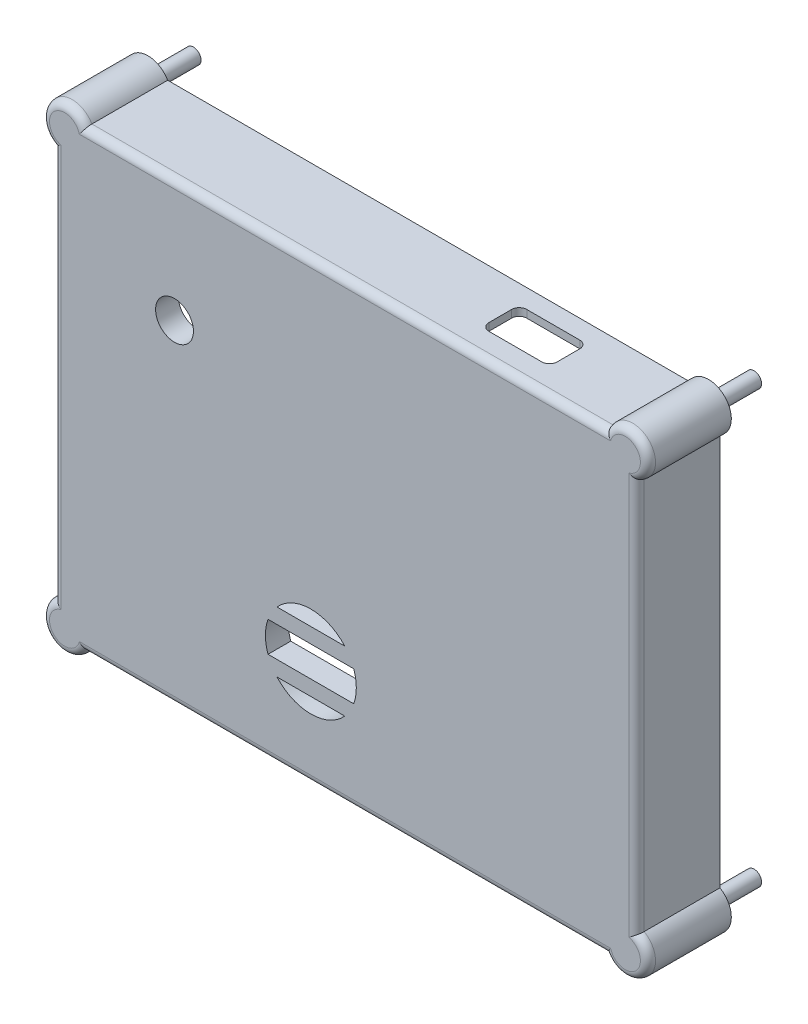
from build123d import *

# Parameters (mm, degrees)
SKETCH2_R                  = 1.75
BOSS_EXTRUDE1_DEPTH        = 8
BOSS_EXTRUDE1_DEPTH_BACK   = 12
BOSS_EXTRUDE1_2_DEPTH      = 8
BOSS_EXTRUDE1_2_DEPTH_BACK = 12
BOSS_EXTRUDE1_3_DEPTH      = 8
BOSS_EXTRUDE1_3_DEPTH_BACK = 12
BOSS_EXTRUDE1_4_DEPTH      = 8
BOSS_EXTRUDE1_4_DEPTH_BACK = 12
SKETCH3_W                  = 77
SKETCH3_H                  = 60
SKETCH3_W_2                = 71
SKETCH3_H_2                = 54
BOSS_EXTRUDE2_DEPTH        = 8
SKETCH4_W                  = 77
SKETCH4_H                  = 60
BOSS_EXTRUDE3_DEPTH        = 3
CUT_EXTRUDE6_DEPTH         = 20
CUT_EXTRUDE8_DEPTH         = 13
CUT_EXTRUDE9_DEPTH         = 10
SKETCH17_R                 = 1
BOSS_EXTRUDE5_DEPTH        = 6
BOSS_EXTRUDE5_DEPTH_BACK   = 7
FILLET1_R                  = 1
BOSS_EXTRUDE6_DEPTH        = 11
FILLET3_R                  = 1
SKETCH20_R                 = 2.5
CUT_EXTRUDE10_DEPTH        = 10
SKETCH22_W                 = 34.401923789
SKETCH22_H                 = 2
CUT_EXTRUDE11_DEPTH        = 8


with BuildPart() as part:
    # Sketch2 → Boss-Extrude1 (new body, two sides)
    with BuildSketch(Plane.XY) as boss_extrude1_sk:
        with BuildLine():
            Line((-35.5, -27), (-25.5, -27))
            ThreePointArc((-25.5, -27), (-28.428932188, -19.928932188), (-35.5, -17))
            Line((-35.5, -17), (-35.5, -27))
        make_face()
        with Locations((-33, -23)):
            Circle(SKETCH2_R, mode=Mode.SUBTRACT)
    extrude(amount=BOSS_EXTRUDE1_DEPTH)
    extrude(boss_extrude1_sk.sketch, amount=-BOSS_EXTRUDE1_DEPTH_BACK)



with BuildPart() as body_2:
    # Sketch2 → Boss-Extrude1 2 (new body, two sides)
    with BuildSketch(Plane.XY) as boss_extrude1_2_sk:
        with BuildLine():
            Line((35.5, 27), (35.5, 17))
            ThreePointArc((35.5, 17), (28.428932188, 19.928932188), (25.5, 27))
            Line((25.5, 27), (35.5, 27))
        make_face()
        with Locations((33, 21)):
            Circle(SKETCH2_R, mode=Mode.SUBTRACT)
    extrude(amount=BOSS_EXTRUDE1_2_DEPTH)
    extrude(boss_extrude1_2_sk.sketch, amount=-BOSS_EXTRUDE1_2_DEPTH_BACK)


with BuildPart() as body_3:
    # Sketch2 → Boss-Extrude1 3 (new body, two sides)
    with BuildSketch(Plane.XY) as boss_extrude1_3_sk:
        with BuildLine():
            Line((-35.5, 27), (-25.5, 27))
            ThreePointArc((-25.5, 27), (-28.428932188, 19.928932188), (-35.5, 17))
            Line((-35.5, 17), (-35.5, 27))
        make_face()
        with Locations((-33, 21)):
            Circle(SKETCH2_R, mode=Mode.SUBTRACT)
    extrude(amount=BOSS_EXTRUDE1_3_DEPTH)
    extrude(boss_extrude1_3_sk.sketch, amount=-BOSS_EXTRUDE1_3_DEPTH_BACK)


with BuildPart() as body_4:
    # Sketch2 → Boss-Extrude1 4 (new body, two sides)
    with BuildSketch(Plane.XY) as boss_extrude1_4_sk:
        with BuildLine():
            Line((35.5, -17), (35.5, -27))
            Line((35.5, -27), (25.5, -27))
            ThreePointArc((25.5, -27), (28.428932188, -19.928932188), (35.5, -17))
        make_face()
        with Locations((33, -23)):
            Circle(SKETCH2_R, mode=Mode.SUBTRACT)
    extrude(amount=BOSS_EXTRUDE1_4_DEPTH)
    extrude(boss_extrude1_4_sk.sketch, amount=-BOSS_EXTRUDE1_4_DEPTH_BACK)


with BuildPart() as part_1:
    add(part.part)

    add(body_2.part)  # Boss-Extrude2 merges body 2

    add(body_3.part)  # Boss-Extrude2 merges body 3

    add(body_4.part)  # Boss-Extrude2 merges body 4
    # Sketch3 → Boss-Extrude2 (add)
    with BuildSketch(Plane.XY):
        Rectangle(SKETCH3_W, SKETCH3_H)
        Rectangle(SKETCH3_W_2, SKETCH3_H_2, mode=Mode.SUBTRACT)
    extrude(amount=BOSS_EXTRUDE2_DEPTH)

    # Sketch4 → Boss-Extrude3 (add)
    with BuildSketch(Plane.XY.offset(8)):
        Rectangle(SKETCH4_W, SKETCH4_H)
    extrude(amount=BOSS_EXTRUDE3_DEPTH)

    # Sketch12 → Cut-Extrude6 (cut)
    with BuildSketch(Plane(origin=(0, 0, -12), x_dir=(-1, 0, 0), z_dir=(0, 0, -1))):
        with BuildLine():
            Line((-35.5, -27), (-25.5, -27))
            ThreePointArc((-25.5, -27), (-28.428932188, -19.928932188), (-35.5, -17))
            Line((-35.5, -17), (-35.5, -27))
        make_face()
        with BuildLine():
            Line((35.5, -27), (35.5, -17))
            ThreePointArc((35.5, -17), (28.428932188, -19.928932188), (25.5, -27))
            Line((25.5, -27), (35.5, -27))
        make_face()
        with BuildLine():
            Line((35.5, 17), (35.5, 27))
            Line((35.5, 27), (25.5, 27))
            ThreePointArc((25.5, 27), (28.428932188, 19.928932188), (35.5, 17))
        make_face()
        with BuildLine():
            Line((-25.5, 27), (-35.5, 27))
            Line((-35.5, 27), (-35.5, 17))
            ThreePointArc((-35.5, 17), (-28.428932188, 19.928932188), (-25.5, 27))
        make_face()
    extrude(amount=-CUT_EXTRUDE6_DEPTH, mode=Mode.SUBTRACT)

    # Sketch14 → Cut-Extrude8 (cut)
    with BuildSketch(Plane(origin=(0, 30, 0), x_dir=(1, 0, 0), z_dir=(0, 1, 0))):
        with BuildLine():
            Line((22.5, -7.5), (15.5, -7.5))
            ThreePointArc((15.5, -7.5), (14.792893219, -7.207106781), (14.5, -6.5))
            Line((14.5, -6.5), (14.5, -3.5))
            ThreePointArc((14.5, -3.5), (14.792893219, -2.792893219), (15.5, -2.5))
            Line((15.5, -2.5), (22.5, -2.5))
            ThreePointArc((22.5, -2.5), (23.207106781, -2.792893219), (23.5, -3.5))
            Line((23.5, -3.5), (23.5, -6.5))
            ThreePointArc((23.5, -6.5), (23.207106781, -7.207106781), (22.5, -7.5))
        make_face()
    extrude(amount=-CUT_EXTRUDE8_DEPTH, mode=Mode.SUBTRACT)

    # Sketch15 → Cut-Extrude9 (cut)
    with BuildSketch(Plane.XY.offset(11)):
        with BuildLine():
            ThreePointArc((-0.027864045, -12), (-4.5, -10), (-8.972135955, -12))
            Line((-8.972135955, -12), (-0.027864045, -12))
        make_face()
        with BuildLine():
            Line((1.156854249, -14), (-10.156854249, -14))
            ThreePointArc((-10.156854249, -14), (-10.5, -16), (-10.156854249, -18))
            Line((-10.156854249, -18), (1.156854249, -18))
            ThreePointArc((1.156854249, -18), (1.413591358, -17.014611872), (1.5, -16))
            ThreePointArc((1.5, -16), (1.413591358, -14.985388128), (1.156854249, -14))
        make_face()
        with BuildLine():
            Line((-0.027864045, -20), (-8.972135955, -20))
            ThreePointArc((-8.972135955, -20), (-4.5, -22), (-0.027864045, -20))
        make_face()
    extrude(amount=-CUT_EXTRUDE9_DEPTH, mode=Mode.SUBTRACT)

    # Sketch17 → Boss-Extrude5 (add, two sides)
    with BuildSketch(Plane(origin=(0, 0, 0), x_dir=(-1, 0, 0), z_dir=(0, 0, -1))) as boss_extrude5_sk:
        with Locations((-37, 28.5)):
            Circle(SKETCH17_R)
        with Locations((37, 28.5)):
            Circle(SKETCH17_R)
        with Locations((37, -28.5)):
            Circle(SKETCH17_R)
        with Locations((-37, -28.472787798)):
            Circle(SKETCH17_R)
    extrude(amount=BOSS_EXTRUDE5_DEPTH)
    extrude(boss_extrude5_sk.sketch, amount=-BOSS_EXTRUDE5_DEPTH_BACK)

    # Fillet1
    fillet1_edges = [part_1.edges().sort_by_distance(p)[0] for p in [
        (-38.5, 30, 5.5),
        (38.5, 30, 5.5),
        (38.5, -30, 5.5),
        (-38.5, -30, 5.5),
    ]]
    fillet(fillet1_edges, radius=FILLET1_R)

    # Sketch19 → Boss-Extrude6 (add)
    with BuildSketch(Plane(origin=(0, 0, 0), x_dir=(-1, 0, 0), z_dir=(0, 0, -1))):
        with BuildLine():
            Line((38.5, 29), (38.5, 25.901923789))
            ThreePointArc((38.5, 25.901923789), (39.121320344, 30.621320344), (34.401923789, 30))
            Line((34.401923789, 30), (37.5, 30))
            ThreePointArc((37.5, 30), (38.207106781, 29.707106781), (38.5, 29))
        make_face()
        with BuildLine():
            Line((37.5, -30), (34.401923789, -30))
            ThreePointArc((34.401923789, -30), (39.121320344, -30.621320344), (38.5, -25.901923789))
            Line((38.5, -25.901923789), (38.5, -29))
            ThreePointArc((38.5, -29), (38.207106781, -29.707106781), (37.5, -30))
        make_face()
        with BuildLine():
            Line((-38.5, -29), (-38.5, -25.874711587))
            ThreePointArc((-38.5, -25.874711587), (-39.13243436, -30.582935589), (-34.417825937, -30))
            Line((-34.417825937, -30), (-37.5, -30))
            ThreePointArc((-37.5, -30), (-38.207106781, -29.707106781), (-38.5, -29))
        make_face()
        with BuildLine():
            Line((-37.5, 30), (-34.401923789, 30))
            ThreePointArc((-34.401923789, 30), (-39.121320344, 30.621320344), (-38.5, 25.901923789))
            Line((-38.5, 25.901923789), (-38.5, 29))
            ThreePointArc((-38.5, 29), (-38.207106781, 29.707106781), (-37.5, 30))
        make_face()
    extrude(amount=-BOSS_EXTRUDE6_DEPTH)

    # Fillet3
    fillet3_edges = [part_1.edges().sort_by_distance(p)[0] for p in [
        (-38.5, 0, 11),
        (-39.121320344, 30.621320344, 11),
        (0.007951074, -30, 11),
        (-39.121320344, -30.621320344, 11),
        (38.5, 0.013606101, 11),
        (39.13243436, -30.582935589, 11),
        (0, 30, 11),
        (39.121320344, 30.621320344, 11),
    ]]
    fillet(fillet3_edges, radius=FILLET3_R)

    # Sketch20 → Cut-Extrude10 (cut)
    with BuildSketch(Plane.XY.offset(11)):
        with Locations((-22.5, 14)):
            Circle(SKETCH20_R)
    extrude(amount=-CUT_EXTRUDE10_DEPTH, mode=Mode.SUBTRACT)

    # Sketch22 → Cut-Extrude11 (cut)
    with BuildSketch(Plane(origin=(0, 0, 0), x_dir=(-1, 0, 0), z_dir=(0, 0, -1))):
        with Locations((-17.200961895, 28)):
            Rectangle(SKETCH22_W, SKETCH22_H)
    extrude(amount=-CUT_EXTRUDE11_DEPTH, mode=Mode.SUBTRACT)


solid = part_1.part
